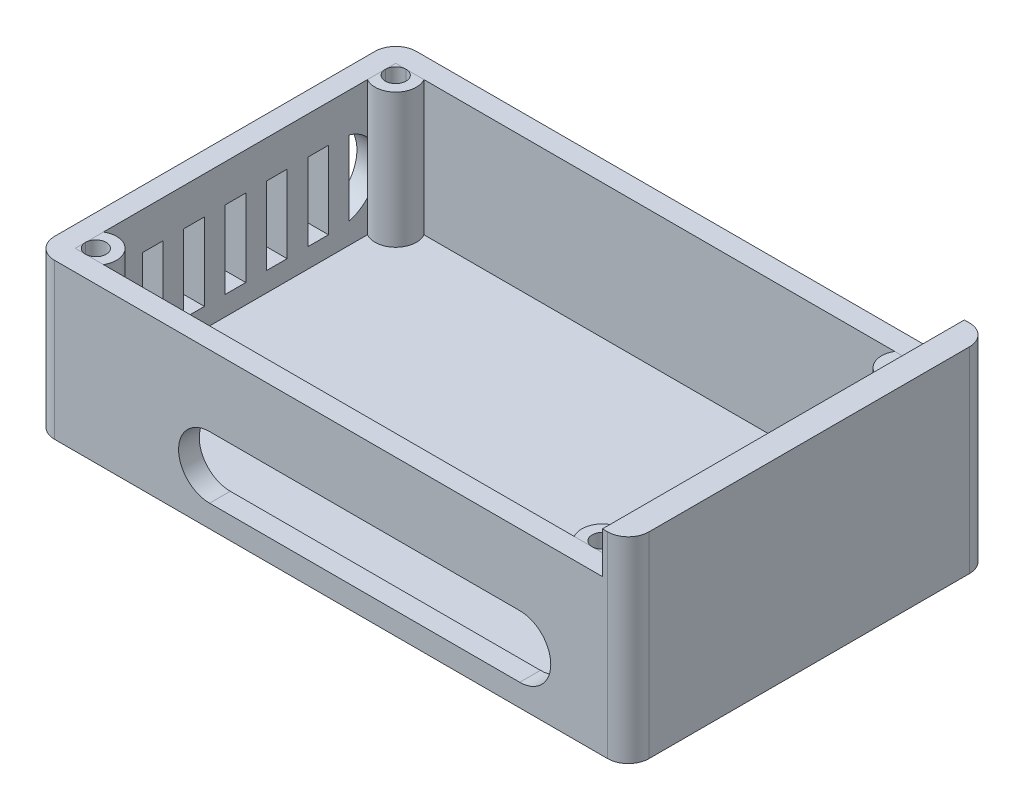
from build123d import *

# Parameters (mm, degrees)
SKETCH1_W             = 139.7
SKETCH1_H             = 88.9
BOSS_EXTRUDE1_DEPTH   = 38.1
SHELL1_T              = -5.08
SKETCH2_W             = 5.08
SKETCH2_H             = 19.05
CUT_EXTRUDE1_DEPTH    = 5.08
CUT_EXTRUDE2_DEPTH    = 5.08
BOSS_EXTRUDE2_DEPTH   = 33.02
BOSS_EXTRUDE2_2_DEPTH = 33.02
BOSS_EXTRUDE2_3_DEPTH = 33.02
BOSS_EXTRUDE2_4_DEPTH = 33.02
BOSS_EXTRUDE2_5_DEPTH = 33.02
BOSS_EXTRUDE2_6_DEPTH = 33.02
BOSS_EXTRUDE2_7_DEPTH = 33.02
BOSS_EXTRUDE2_8_DEPTH = 33.02
SKETCH5_W             = 6.35
SKETCH5_H             = 88.9
BOSS_EXTRUDE3_DEPTH   = 38.1
SKETCH6_W             = 6.35
SKETCH6_H             = 88.9
BOSS_EXTRUDE4_DEPTH   = 10.16
FILLET1_R             = 5.08


with BuildPart() as part:
    # Sketch1 → Boss-Extrude1 (new body)
    with BuildSketch(Plane(origin=(0, 0, 0), x_dir=(1, 0, 0), z_dir=(0, 1, 0))):
        with Locations((-16.282684825, 6.745330739)):
            Rectangle(SKETCH1_W, SKETCH1_H)
    extrude(amount=BOSS_EXTRUDE1_DEPTH)

    # Shell1
    shell1_openings = [part.faces().sort_by_distance(p)[0] for p in [
        (-16.282684825, 38.1, -6.745330739),
    ]]
    offset(amount=SHELL1_T, openings=shell1_openings, kind=Kind.INTERSECTION)

    # Sketch2 → Cut-Extrude1 (cut)
    with BuildSketch(Plane.ZY.offset(86.132684825)):
        with BuildLine():
            Line((-34.685330739, 10.210424953), (-34.685330739, 28.570601967))
            ThreePointArc((-34.685330739, 28.570601967), (-41.670330739, 19.39051346), (-34.685330739, 10.210424953))
        make_face()
        with Locations((-27.065330739, 19.39051346)):
            Rectangle(SKETCH2_W, SKETCH2_H)
        with Locations((-16.905330739, 19.39051346)):
            Rectangle(SKETCH2_W, SKETCH2_H)
        with Locations((-6.745330739, 19.39051346)):
            Rectangle(SKETCH2_W, SKETCH2_H)
        with Locations((3.414669261, 19.39051346)):
            Rectangle(SKETCH2_W, SKETCH2_H)
        with Locations((13.574669261, 19.39051346)):
            Rectangle(SKETCH2_W, SKETCH2_H)
        with BuildLine():
            ThreePointArc((21.194669261, 10.210424953), (28.179669261, 19.39051346), (21.194669261, 28.570601967))
            Line((21.194669261, 28.570601967), (21.194669261, 10.210424953))
        make_face()
    extrude(amount=-CUT_EXTRUDE1_DEPTH, mode=Mode.SUBTRACT)

    # Sketch3 → Cut-Extrude2 (cut)
    with BuildSketch(Plane.XY.offset(37.704669261)):
        with BuildLine():
            Line((33.247315175, 5.461), (-42.952684825, 5.461))
            ThreePointArc((-42.952684825, 5.461), (-50.572684825, 13.081), (-42.952684825, 20.701))
            Line((-42.952684825, 20.701), (33.247315175, 20.701))
            ThreePointArc((33.247315175, 20.701), (40.867315175, 13.081), (33.247315175, 5.461))
        make_face()
    extrude(amount=-CUT_EXTRUDE2_DEPTH, mode=Mode.SUBTRACT)

    # Sketch5 → Boss-Extrude3 (add)
    with BuildSketch(Plane(origin=(0, 38.1, 0), x_dir=(1, 0, 0), z_dir=(0, 1, 0))):
        with Locations((56.742315175, 6.745330739)):
            Rectangle(SKETCH5_W, SKETCH5_H)
    extrude(amount=-BOSS_EXTRUDE3_DEPTH)

    # Sketch6 → Boss-Extrude4 (add)
    with BuildSketch(Plane(origin=(0, 38.1, 0), x_dir=(1, 0, 0), z_dir=(0, 1, 0))):
        with Locations((56.742315175, 6.745330739)):
            Rectangle(SKETCH6_W, SKETCH6_H)
    extrude(amount=BOSS_EXTRUDE4_DEPTH)

    # Fillet1
    fillet1_edges = [part.edges().sort_by_distance(p)[0] for p in [
        (59.917315175, 24.13, -51.195330739),
        (59.917315175, 24.13, 37.704669261),
        (-86.132684825, 19.05, -51.195330739),
        (-86.132684825, 19.05, 37.704669261),
    ]]
    fillet(fillet1_edges, radius=FILLET1_R)


with BuildPart() as body_2:
    # Sketch4 → Boss-Extrude2 (new body)
    with BuildSketch(Plane(origin=(0, 38.1, 0), x_dir=(1, 0, 0), z_dir=(0, 1, 0))):
        with BuildLine():
            Line((48.487315175, 46.115330739), (45.947315175, 46.115330739))
            ThreePointArc((45.947315175, 46.115330739), (47.743366399, 45.371381964), (48.487315175, 43.575330739))
            Line((48.487315175, 43.575330739), (48.487315175, 46.115330739))
        make_face()
    extrude(amount=-BOSS_EXTRUDE2_DEPTH)


with BuildPart() as body_3:
    # Sketch4 → Boss-Extrude2 2 (new body)
    with BuildSketch(Plane(origin=(0, 38.1, 0), x_dir=(1, 0, 0), z_dir=(0, 1, 0))):
        with BuildLine():
            Line((45.947315175, 46.115330739), (41.547906124, 46.115330739))
            ThreePointArc((41.547906124, 46.115330739), (42.355212727, 39.983228291), (48.487315175, 39.175921688))
            Line((48.487315175, 39.175921688), (48.487315175, 43.575330739))
            ThreePointArc((48.487315175, 43.575330739), (44.151263951, 41.779279515), (45.947315175, 46.115330739))
        make_face()
    extrude(amount=-BOSS_EXTRUDE2_2_DEPTH)


with BuildPart() as body_4:
    # Sketch4 → Boss-Extrude2 3 (new body)
    with BuildSketch(Plane(origin=(0, 38.1, 0), x_dir=(1, 0, 0), z_dir=(0, 1, 0))):
        with BuildLine():
            Line((48.487315175, -32.624669261), (48.487315175, -30.084669261))
            ThreePointArc((48.487315175, -30.084669261), (47.743366399, -31.880720485), (45.947315175, -32.624669261))
            Line((45.947315175, -32.624669261), (48.487315175, -32.624669261))
        make_face()
    extrude(amount=-BOSS_EXTRUDE2_3_DEPTH)


with BuildPart() as body_5:
    # Sketch4 → Boss-Extrude2 4 (new body)
    with BuildSketch(Plane(origin=(0, 38.1, 0), x_dir=(1, 0, 0), z_dir=(0, 1, 0))):
        with BuildLine():
            Line((48.487315175, -30.084669261), (48.487315175, -25.685260209))
            ThreePointArc((48.487315175, -25.685260209), (42.355212727, -26.492566812), (41.547906124, -32.624669261))
            Line((41.547906124, -32.624669261), (45.947315175, -32.624669261))
            ThreePointArc((45.947315175, -32.624669261), (44.151263951, -28.288618036), (48.487315175, -30.084669261))
        make_face()
    extrude(amount=-BOSS_EXTRUDE2_4_DEPTH)


with BuildPart() as body_6:
    # Sketch4 → Boss-Extrude2 5 (new body)
    with BuildSketch(Plane(origin=(0, 38.1, 0), x_dir=(1, 0, 0), z_dir=(0, 1, 0))):
        with BuildLine():
            ThreePointArc((-78.512684916, -32.624669261), (-80.308736081, -31.880720453), (-81.052684825, -30.084669261))
            Line((-81.052684825, -30.084669261), (-81.052684825, -32.624669261))
            Line((-81.052684825, -32.624669261), (-78.512684916, -32.624669261))
        make_face()
    extrude(amount=-BOSS_EXTRUDE2_5_DEPTH)


with BuildPart() as body_7:
    # Sketch4 → Boss-Extrude2 6 (new body)
    with BuildSketch(Plane(origin=(0, 38.1, 0), x_dir=(1, 0, 0), z_dir=(0, 1, 0))):
        with BuildLine():
            ThreePointArc((-73.432684825, -30.084669261), (-75.972684825, -25.685260209), (-81.052684825, -25.685260209))
            Line((-81.052684825, -25.685260209), (-81.052684825, -30.084669261))
            ThreePointArc((-81.052684825, -30.084669261), (-78.512684825, -27.544669261), (-75.972684825, -30.084669261))
            ThreePointArc((-75.972684825, -30.084669261), (-76.716633633, -31.880720517), (-78.512684916, -32.624669261))
            Line((-78.512684916, -32.624669261), (-74.113275774, -32.624669261))
            ThreePointArc((-74.113275774, -32.624669261), (-73.605781627, -31.39947001), (-73.432684825, -30.084669261))
        make_face()
    extrude(amount=-BOSS_EXTRUDE2_6_DEPTH)


with BuildPart() as body_8:
    # Sketch4 → Boss-Extrude2 7 (new body)
    with BuildSketch(Plane(origin=(0, 38.1, 0), x_dir=(1, 0, 0), z_dir=(0, 1, 0))):
        with BuildLine():
            ThreePointArc((-81.052684825, 43.575330739), (-80.308736057, 45.371381956), (-78.512684847, 46.115330739))
            Line((-78.512684847, 46.115330739), (-81.052684825, 46.115330739))
            Line((-81.052684825, 46.115330739), (-81.052684825, 43.575330739))
        make_face()
    extrude(amount=-BOSS_EXTRUDE2_7_DEPTH)


with BuildPart() as body_9:
    # Sketch4 → Boss-Extrude2 8 (new body)
    with BuildSketch(Plane(origin=(0, 38.1, 0), x_dir=(1, 0, 0), z_dir=(0, 1, 0))):
        with BuildLine():
            ThreePointArc((-78.512684847, 46.115330739), (-76.716633608, 45.371381971), (-75.972684825, 43.575330739))
            ThreePointArc((-75.972684825, 43.575330739), (-78.512684825, 41.035330739), (-81.052684825, 43.575330739))
            Line((-81.052684825, 43.575330739), (-81.052684825, 39.175921688))
            ThreePointArc((-81.052684825, 39.175921688), (-75.972684825, 39.175921688), (-73.432684825, 43.575330739))
            ThreePointArc((-73.432684825, 43.575330739), (-73.605781627, 44.890131488), (-74.113275774, 46.115330739))
            Line((-74.113275774, 46.115330739), (-78.512684847, 46.115330739))
        make_face()
    extrude(amount=-BOSS_EXTRUDE2_8_DEPTH)


solid = Compound([part.part, body_2.part, body_3.part, body_4.part, body_5.part, body_6.part, body_7.part, body_8.part, body_9.part])
